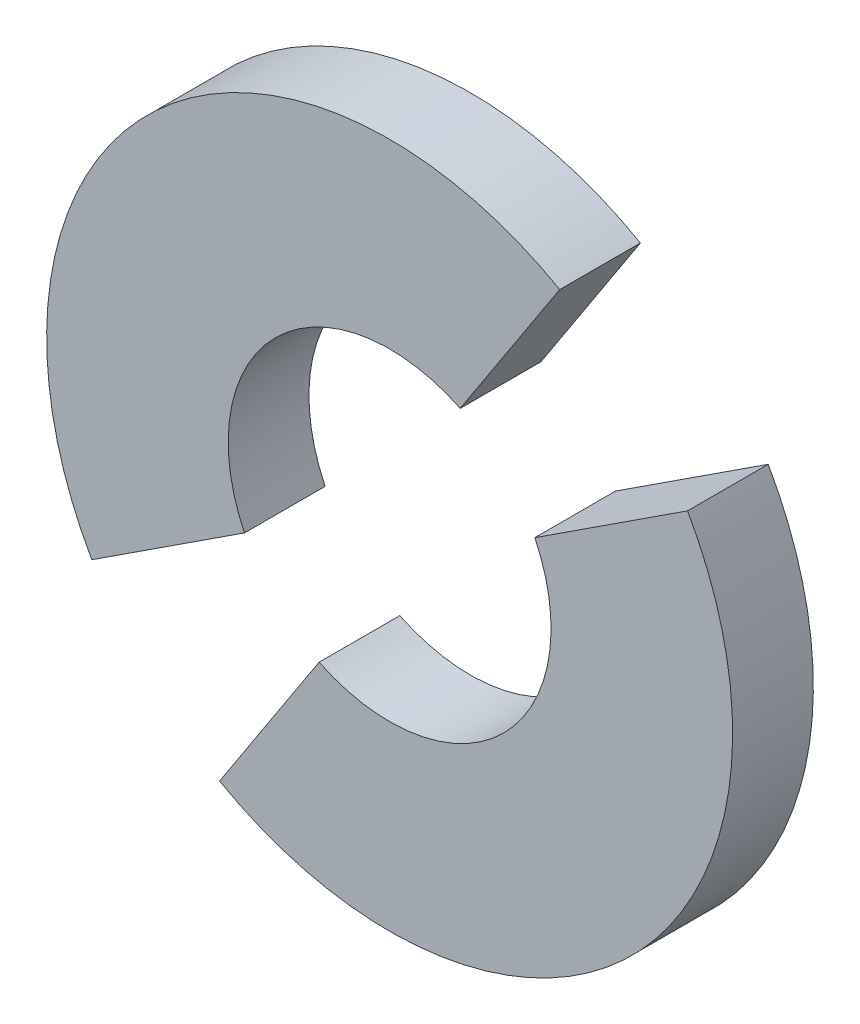
from build123d import *

# Parameters (mm, degrees)
BOSS_EXTRUDE2_DEPTH   = 6.35
BOSS_EXTRUDE2_2_DEPTH = 6.35


with BuildPart() as part:
    # Sketch2 → Boss-Extrude2 (new body)
    with BuildSketch(Plane.XY):
        with BuildLine():
            Line((-10.55661598, -20.381281409), (-18.387924388, -32.394484249))
            ThreePointArc((-18.387924388, -32.394484249), (14.077647841, -28.041805745), (18.430326345, 4.423766484))
            Line((18.430326345, 4.423766484), (6.417123505, -3.407541924))
            ThreePointArc((6.417123505, -3.407541924), (3.974859705, -17.939017609), (-10.55661598, -20.381281409))
        make_face()
    extrude(amount=BOSS_EXTRUDE2_DEPTH)


with BuildPart() as body_2:
    # Sketch2 → Boss-Extrude2 2 (new body)
    with BuildSketch(Plane.XY):
        with BuildLine():
            Line((-28.441119177, -22.341289459), (-16.427916338, -14.509981051))
            ThreePointArc((-16.427916338, -14.509981051), (-13.985652537, 0.021494634), (0.545823148, 2.463758434))
            Line((0.545823148, 2.463758434), (8.377131555, 14.476961274))
            ThreePointArc((8.377131555, 14.476961274), (-24.088440674, 10.12428277), (-28.441119177, -22.341289459))
        make_face()
    extrude(amount=BOSS_EXTRUDE2_2_DEPTH)


solid = Compound([part.part, body_2.part])
